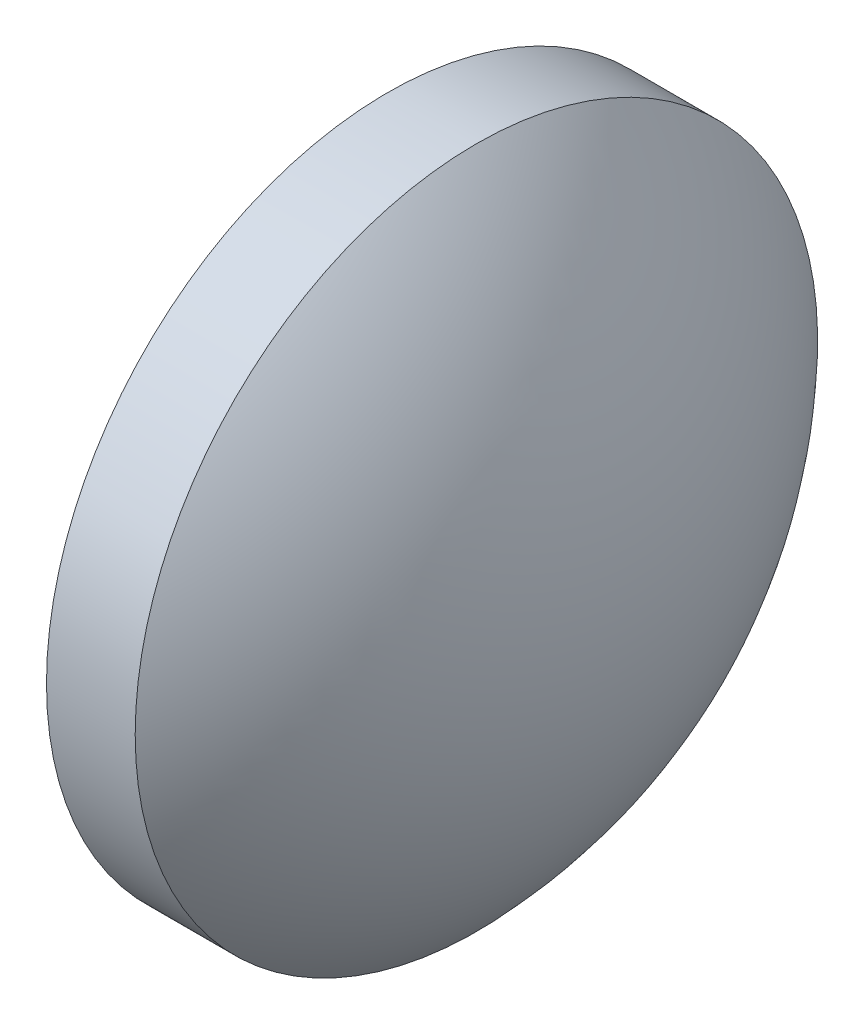
from build123d import *


with BuildPart() as part:
    # 草图1 → 旋转1 (revolve)
    with BuildSketch(Plane.XY):
        with BuildLine():
            Line((408.596593975, 122.183330376), (408.596593975, 127.183330376))
            Line((408.596593975, 127.183330376), (409.896593975, 127.183330376))
            ThreePointArc((409.896593975, 127.183330376), (411.378049984, 124.87591278), (411.896593975, 122.183330376))
            Line((411.896593975, 122.183330376), (408.596593975, 122.183330376))
        make_face()
    revolve(axis=Axis((407.454364282, 122.183330376, 0), (1, 0, 0)))


solid = part.part
